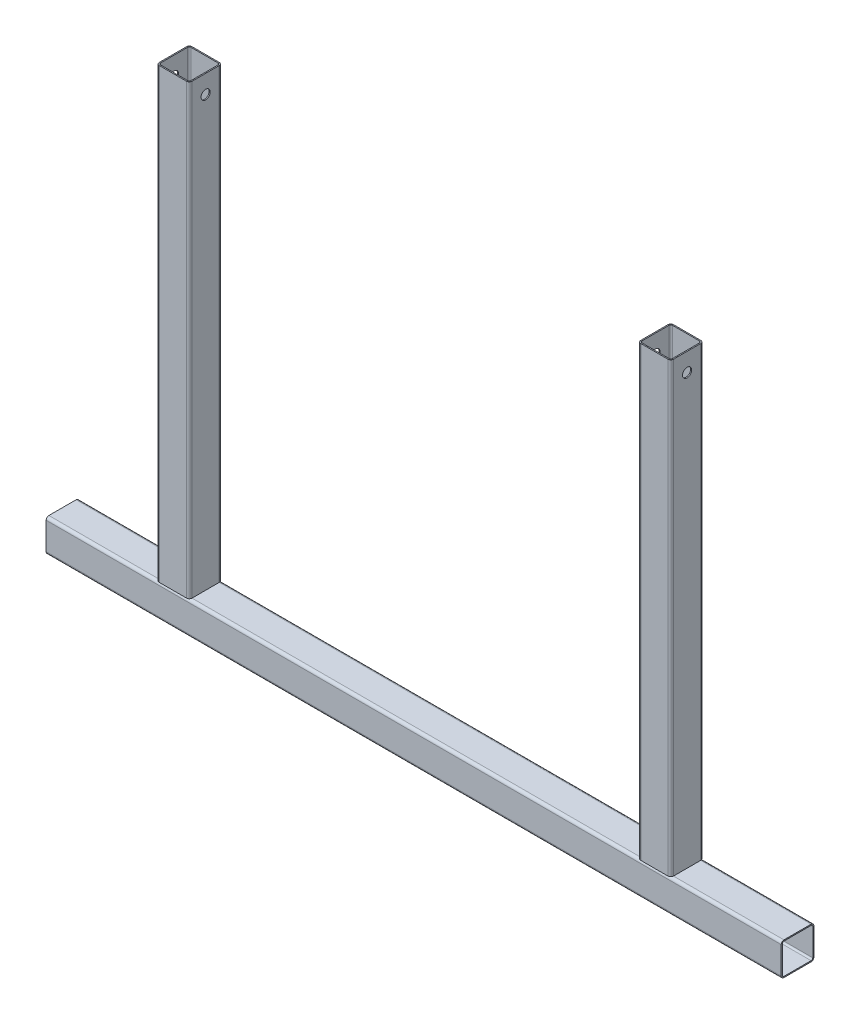
from build123d import *

# Parameters (mm, degrees)
STRUCTURAL_MEMBER1_DEPTH   = 800
STRUCTURAL_MEMBER1_2_DEPTH = 506
STRUCTURAL_MEMBER1_3_DEPTH = 506
SKETCH12_R                 = 5
CUT_EXTRUDE2_DEPTH         = 645.470201018
CUT_EXTRUDE2_DEPTH_BACK    = 645.470201018


with BuildPart() as part:
    # Sketch11 → Structural Member1 (new body)
    with BuildSketch(Plane.YZ.offset(-400)):
        with BuildLine():
            Line((-14.8, -17.8), (14.8, -17.8))
            ThreePointArc((14.8, -17.8), (16.921320344, -16.921320344), (17.8, -14.8))
            Line((17.8, -14.8), (17.8, 14.8))
            ThreePointArc((17.8, 14.8), (16.921320344, 16.921320344), (14.8, 17.8))
            Line((14.8, 17.8), (-14.8, 17.8))
            ThreePointArc((-14.8, 17.8), (-16.921320344, 16.921320344), (-17.8, 14.8))
            Line((-17.8, 14.8), (-17.8, -14.8))
            ThreePointArc((-17.8, -14.8), (-16.921320344, -16.921320344), (-14.8, -17.8))
        make_face()
        with BuildLine():
            Line((-14.8, 16.6), (14.8, 16.6))
            ThreePointArc((14.8, 16.6), (16.072792206, 16.072792206), (16.6, 14.8))
            Line((16.6, 14.8), (16.6, -14.8))
            ThreePointArc((16.6, -14.8), (16.072792206, -16.072792206), (14.8, -16.6))
            Line((14.8, -16.6), (-14.8, -16.6))
            ThreePointArc((-14.8, -16.6), (-16.072792206, -16.072792206), (-16.6, -14.8))
            Line((-16.6, -14.8), (-16.6, 14.8))
            ThreePointArc((-16.6, 14.8), (-16.072792206, 16.072792206), (-14.8, 16.6))
        make_face(mode=Mode.SUBTRACT)
    extrude(amount=STRUCTURAL_MEMBER1_DEPTH)


with BuildPart() as body_2:
    # Sketch11 on segment 2 (carried to segment 2) → Structural Member1 2 (new body)
    with BuildSketch(Plane(origin=(-262, -1, 0), x_dir=(-1, 0, 0), z_dir=(0, 1, 0))):
        with BuildLine():
            Line((-14.8, -17.8), (14.8, -17.8))
            ThreePointArc((14.8, -17.8), (16.921320344, -16.921320344), (17.8, -14.8))
            Line((17.8, -14.8), (17.8, 14.8))
            ThreePointArc((17.8, 14.8), (16.921320344, 16.921320344), (14.8, 17.8))
            Line((14.8, 17.8), (-14.8, 17.8))
            ThreePointArc((-14.8, 17.8), (-16.921320344, 16.921320344), (-17.8, 14.8))
            Line((-17.8, 14.8), (-17.8, -14.8))
            ThreePointArc((-17.8, -14.8), (-16.921320344, -16.921320344), (-14.8, -17.8))
        make_face()
        with BuildLine():
            Line((-14.8, 16.6), (14.8, 16.6))
            ThreePointArc((14.8, 16.6), (16.072792206, 16.072792206), (16.6, 14.8))
            Line((16.6, 14.8), (16.6, -14.8))
            ThreePointArc((16.6, -14.8), (16.072792206, -16.072792206), (14.8, -16.6))
            Line((14.8, -16.6), (-14.8, -16.6))
            ThreePointArc((-14.8, -16.6), (-16.072792206, -16.072792206), (-16.6, -14.8))
            Line((-16.6, -14.8), (-16.6, 14.8))
            ThreePointArc((-16.6, 14.8), (-16.072792206, 16.072792206), (-14.8, 16.6))
        make_face(mode=Mode.SUBTRACT)
    extrude(amount=STRUCTURAL_MEMBER1_2_DEPTH)

    # Structural Member1 2 end butt 1
    split(bisect_by=Plane(origin=(-262, 17.8, 0), x_dir=(-1, 0, 0), z_dir=(0, 1, 0)), keep=Keep.TOP)


with BuildPart() as body_3:
    # Sketch11 on segment 3 (carried to segment 3) → Structural Member1 3 (new body)
    with BuildSketch(Plane(origin=(262, -1, 0), x_dir=(-1, 0, 0), z_dir=(0, 1, 0))):
        with BuildLine():
            Line((-14.8, -17.8), (14.8, -17.8))
            ThreePointArc((14.8, -17.8), (16.921320344, -16.921320344), (17.8, -14.8))
            Line((17.8, -14.8), (17.8, 14.8))
            ThreePointArc((17.8, 14.8), (16.921320344, 16.921320344), (14.8, 17.8))
            Line((14.8, 17.8), (-14.8, 17.8))
            ThreePointArc((-14.8, 17.8), (-16.921320344, 16.921320344), (-17.8, 14.8))
            Line((-17.8, 14.8), (-17.8, -14.8))
            ThreePointArc((-17.8, -14.8), (-16.921320344, -16.921320344), (-14.8, -17.8))
        make_face()
        with BuildLine():
            Line((-14.8, 16.6), (14.8, 16.6))
            ThreePointArc((14.8, 16.6), (16.072792206, 16.072792206), (16.6, 14.8))
            Line((16.6, 14.8), (16.6, -14.8))
            ThreePointArc((16.6, -14.8), (16.072792206, -16.072792206), (14.8, -16.6))
            Line((14.8, -16.6), (-14.8, -16.6))
            ThreePointArc((-14.8, -16.6), (-16.072792206, -16.072792206), (-16.6, -14.8))
            Line((-16.6, -14.8), (-16.6, 14.8))
            ThreePointArc((-16.6, 14.8), (-16.072792206, 16.072792206), (-14.8, 16.6))
        make_face(mode=Mode.SUBTRACT)
    extrude(amount=STRUCTURAL_MEMBER1_3_DEPTH)

    # Structural Member1 3 end butt 1
    split(bisect_by=Plane(origin=(262, 17.8, 0), x_dir=(-1, 0, 0), z_dir=(0, 1, 0)), keep=Keep.TOP)


with BuildPart() as cut_extrude2_tool:
    # Sketch12 → Cut-Extrude2 (new, two sides)
    with BuildSketch(Plane(origin=(0, 0, 0), x_dir=(0, 0, -1), z_dir=(1, 0, 0))) as cut_extrude2_sk:
        with Locations((0, 485)):
            Circle(SKETCH12_R)
    extrude(amount=CUT_EXTRUDE2_DEPTH)
    extrude(cut_extrude2_sk.sketch, amount=-CUT_EXTRUDE2_DEPTH_BACK)


with BuildPart() as body_2_1:
    add(body_2.part)

    # Cut-Extrude2: cut by cut_extrude2_tool
    add(cut_extrude2_tool.part, mode=Mode.SUBTRACT)


with BuildPart() as body_3_1:
    add(body_3.part)

    # Cut-Extrude2: cut by cut_extrude2_tool
    add(cut_extrude2_tool.part, mode=Mode.SUBTRACT)


solid = Compound([part.part, body_2_1.part, body_3_1.part])
